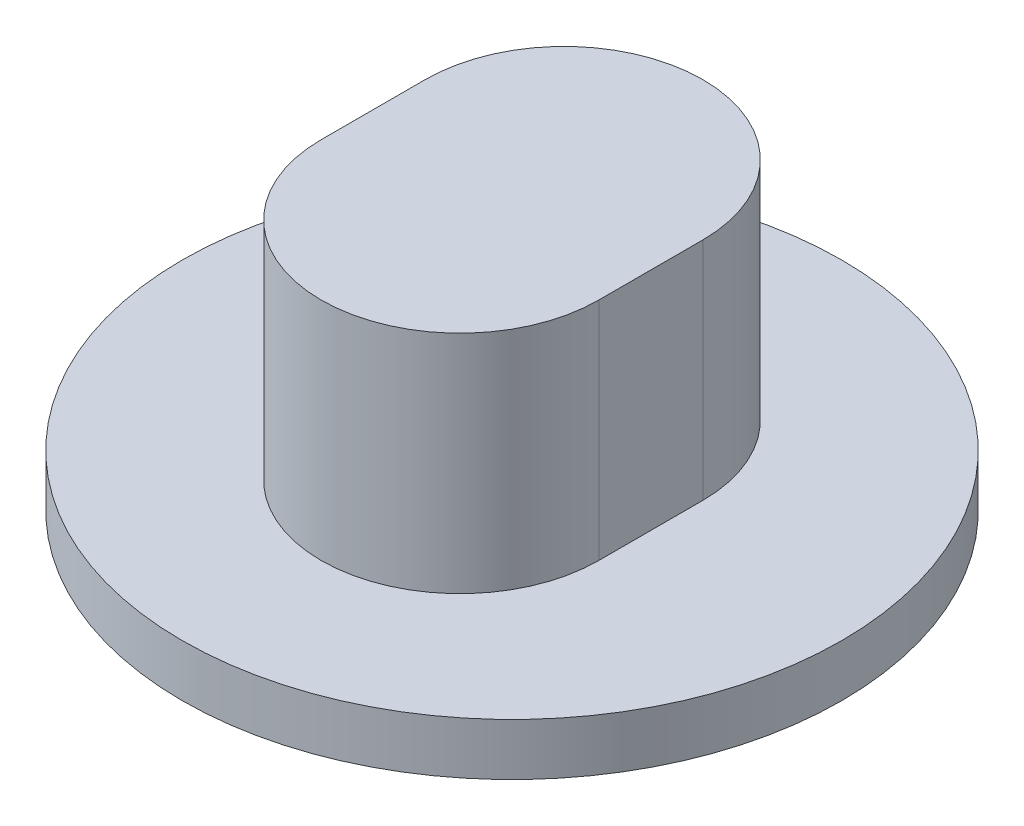
from build123d import *

# Parameters (mm, degrees)
SKETCH1_R           = 19
BOSS_EXTRUDE1_DEPTH = 3
BOSS_EXTRUDE2_DEPTH = 13


with BuildPart() as part:
    # Sketch1 → Boss-Extrude1 (new body)
    with BuildSketch(Plane(origin=(0, 0, 0), x_dir=(1, 0, 0), z_dir=(0, 1, 0))):
        with Locations(Location((0, 0, 0), (0, 0, 270))):  # turned: the seam where the file's is
            Circle(SKETCH1_R)
    extrude(amount=BOSS_EXTRUDE1_DEPTH)

    # Sketch2 → Boss-Extrude2 (add)
    with BuildSketch(Plane(origin=(0, 3, 0), x_dir=(1, 0, 0), z_dir=(0, 1, 0))):
        with BuildLine():
            Line((-8, -3), (-8, 3))
            ThreePointArc((-8, 3), (0, 11), (8, 3))
            Line((8, 3), (8, -3))
            ThreePointArc((8, -3), (0, -11), (-8, -3))
        make_face()
    extrude(amount=BOSS_EXTRUDE2_DEPTH)


solid = part.part
